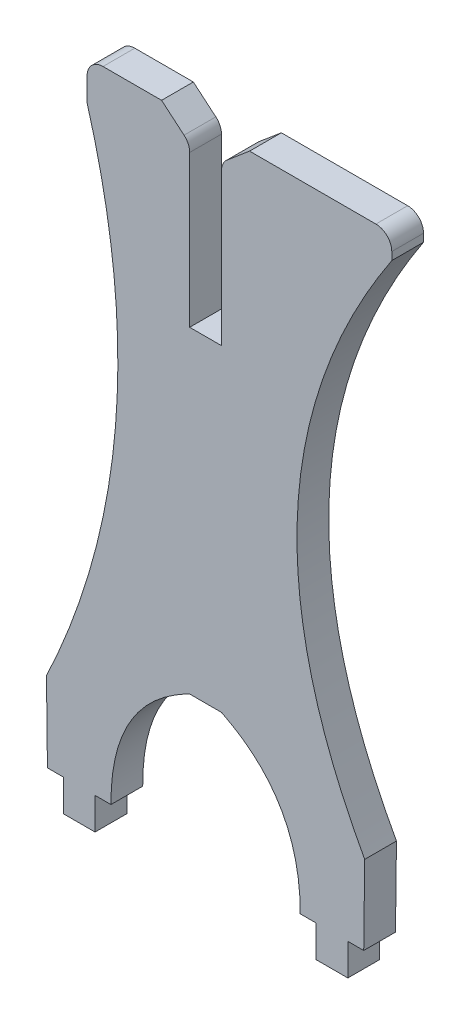
from build123d import *

# Parameters (mm, degrees)
BOSS_EXTRUDE6_DEPTH = 5.08
FILLET21_R          = 2.54
FILLET22_R          = 2.54
FILLET23_R          = 2.54
FILLET24_R          = 2.54


with BuildPart() as part:
    # Sketch1 → Boss-Extrude6 (new body)
    with BuildSketch(Plane.XY):
        with BuildLine():
            Line((0.14834484, -16.543006694), (-0.005888561, -3.843943262))
            add(Edge.make_bspline(
                [(6.500180425, 78.706993306), (18.901808207, 35.989935529), (-0.005888561, -3.843943262)],
                knots=[0, 0, 0, 1, 1, 1], degree=2))
            Line((6.500180425, 78.706993306), (6.500180425, 85.056993306))
            Line((6.500180425, 85.056993306), (18.406430425, 85.056993306))
            Line((18.406430425, 85.056993306), (22.903074533, 81.262968128))
            Line((22.903074533, 81.262968128), (22.903074533, 55.862968128))
            Line((22.903074533, 55.862968128), (27.983074533, 55.862968128))
            Line((27.983074533, 55.862968128), (27.983074533, 81.262968128))
            Line((27.983074533, 81.262968128), (32.479718641, 85.056993306))
            Line((32.479718641, 85.056993306), (55.223636327, 85.056993306))
            Line((55.223636327, 85.056993306), (55.223636327, 81.262968128))
            add(Edge.make_bspline(
                [(55.223636327, 81.262968128), (27.243001732, 39.093980891), (50.892037627, -3.843943262)],
                knots=[0, 0, 0, 1, 1, 1], degree=2))
            Line((50.892037627, -3.843943262), (50.737804225, -16.543006694))
            Line((50.737804225, -16.543006694), (48.197804225, -16.543006694))
            Line((48.197804225, -16.543006694), (48.197804225, -21.623006694))
            Line((48.197804225, -21.623006694), (43.117804225, -21.623006694))
            Line((43.117804225, -21.623006694), (43.117804225, -16.543006694))
            Line((43.117804225, -16.543006694), (40.577804225, -16.543006694))
            add(Edge.make_bspline(
                [(27.983074533, 5.062968128), (40.683819064, -1.22119794), (40.577804225, -16.543006694)],
                knots=[0, 0, 0, 1, 1, 1], degree=2))
            Line((27.983074533, 5.062968128), (22.903074533, 5.062968128))
            add(Edge.make_bspline(
                [(22.903074533, 5.062968128), (10.202330001, -1.22119794), (10.30834484, -16.543006694)],
                knots=[0, 0, 0, 1, 1, 1], degree=2))
            Line((10.30834484, -16.543006694), (7.76834484, -16.543006694))
            Line((7.76834484, -16.543006694), (7.76834484, -21.623006694))
            Line((7.76834484, -21.623006694), (2.68834484, -21.623006694))
            Line((2.68834484, -21.623006694), (2.68834484, -16.543006694))
            Line((2.68834484, -16.543006694), (0.14834484, -16.543006694))
        make_face()
    extrude(amount=BOSS_EXTRUDE6_DEPTH)

    # Fillet21
    fillet21_edges = [part.edges().sort_by_distance(p)[0] for p in [
        (22.903074533, 81.262968128, 2.54),
    ]]
    fillet(fillet21_edges, radius=FILLET21_R)

    # Fillet22
    fillet22_edges = [part.edges().sort_by_distance(p)[0] for p in [
        (27.983074533, 81.262968128, 2.54),
    ]]
    fillet(fillet22_edges, radius=FILLET22_R)

    # Fillet23
    fillet23_edges = [part.edges().sort_by_distance(p)[0] for p in [
        (6.500180425, 85.056993306, 2.54),
    ]]
    fillet(fillet23_edges, radius=FILLET23_R)

    # Fillet24
    fillet24_edges = [part.edges().sort_by_distance(p)[0] for p in [
        (55.223636327, 85.056993306, 2.54),
    ]]
    fillet(fillet24_edges, radius=FILLET24_R)


solid = part.part
